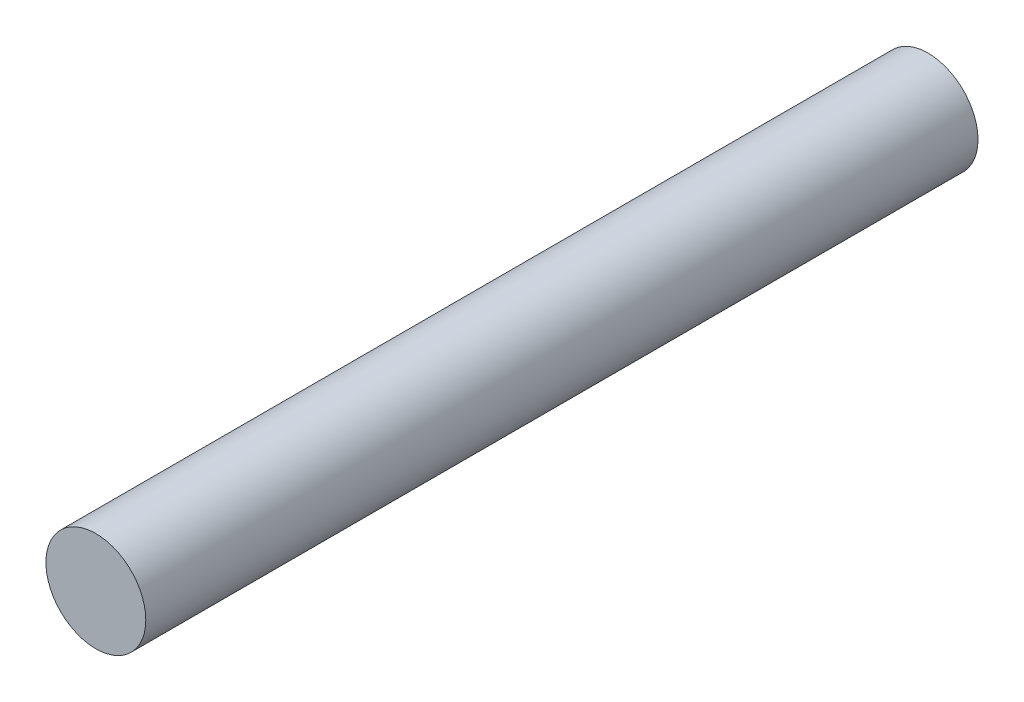
from build123d import *

# Parameters (mm, degrees)
ESQUISSE1_R        = 3
BOSS_EXTRU_1_DEPTH = 50


with BuildPart() as part:
    # Esquisse1 → Boss.-Extru.1 (new body)
    with BuildSketch(Plane.XY):
        Circle(ESQUISSE1_R)
    extrude(amount=BOSS_EXTRU_1_DEPTH)


solid = part.part
